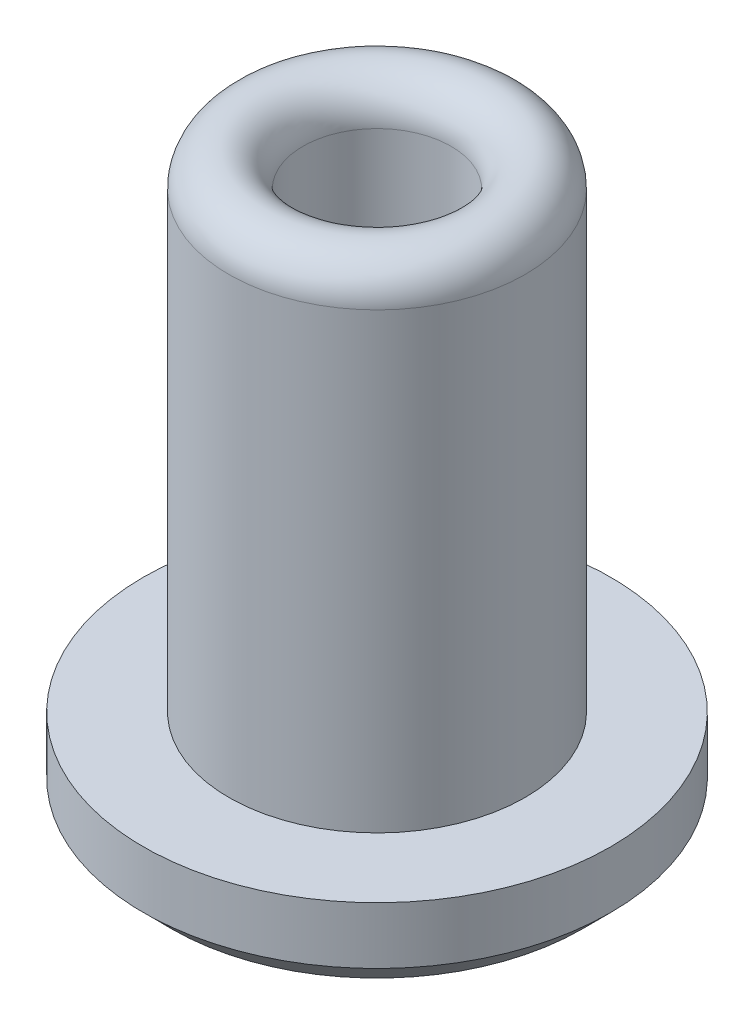
from build123d import *

# Parameters (mm, degrees)
CHAMFER1_SIZE = 0.5


with BuildPart() as part:
    # Sketch1 → Revolve1 (revolve)
    with BuildSketch(Plane.XY):
        with BuildLine():
            Line((0, 0), (0, 0.5))
            Line((0, 0.5), (-0.3, 0.5))
            ThreePointArc((-0.3, 0.5), (-1.007106781, 0.792893219), (-1.3, 1.5))
            Line((-1.3, 1.5), (-1.3, 9.45))
            ThreePointArc((-1.3, 9.45), (-1.95, 10.1), (-2.6, 9.45))
            Line((-2.6, 9.45), (-2.6, 1.5))
            Line((-2.6, 1.5), (-4.1, 1.5))
            Line((-4.1, 1.5), (-4.1, 0))
            Line((-4.1, 0), (0, 0))
        make_face()
    revolve(axis=Axis((0, -1000, 0), (0, 1, 0)))

    # Chamfer1
    chamfer1_edges = [part.edges().sort_by_distance(p)[0] for p in [
        (4.1, 0, 0),
    ]]
    chamfer(chamfer1_edges, length=CHAMFER1_SIZE)


solid = part.part
